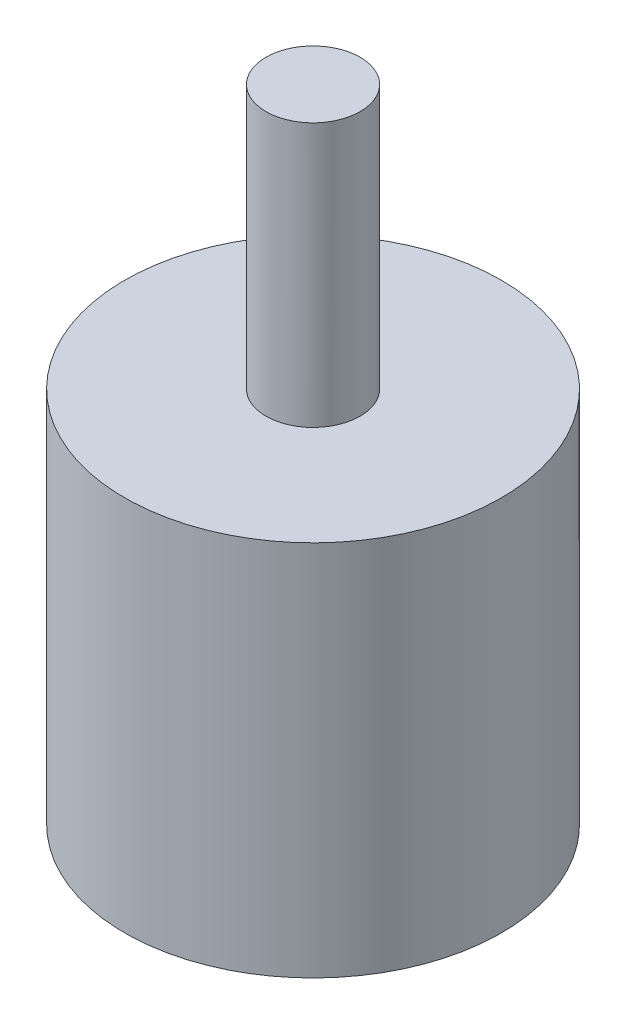
from build123d import *

# Parameters (mm, degrees)
SKETCH1_R           = 3.175
BOSS_EXTRUDE1_DEPTH = 17.78
SKETCH2_R           = 12.7
BOSS_EXTRUDE2_DEPTH = 25.4


with BuildPart() as part:
    # Sketch1 → Boss-Extrude1 (new body)
    with BuildSketch(Plane(origin=(0, 0, 0), x_dir=(1, 0, 0), z_dir=(0, 1, 0))):
        Circle(SKETCH1_R)
    extrude(amount=BOSS_EXTRUDE1_DEPTH)

    # Sketch2 → Boss-Extrude2 (add)
    with BuildSketch(Plane.XZ):
        Circle(SKETCH2_R)
    extrude(amount=BOSS_EXTRUDE2_DEPTH)


solid = part.part
